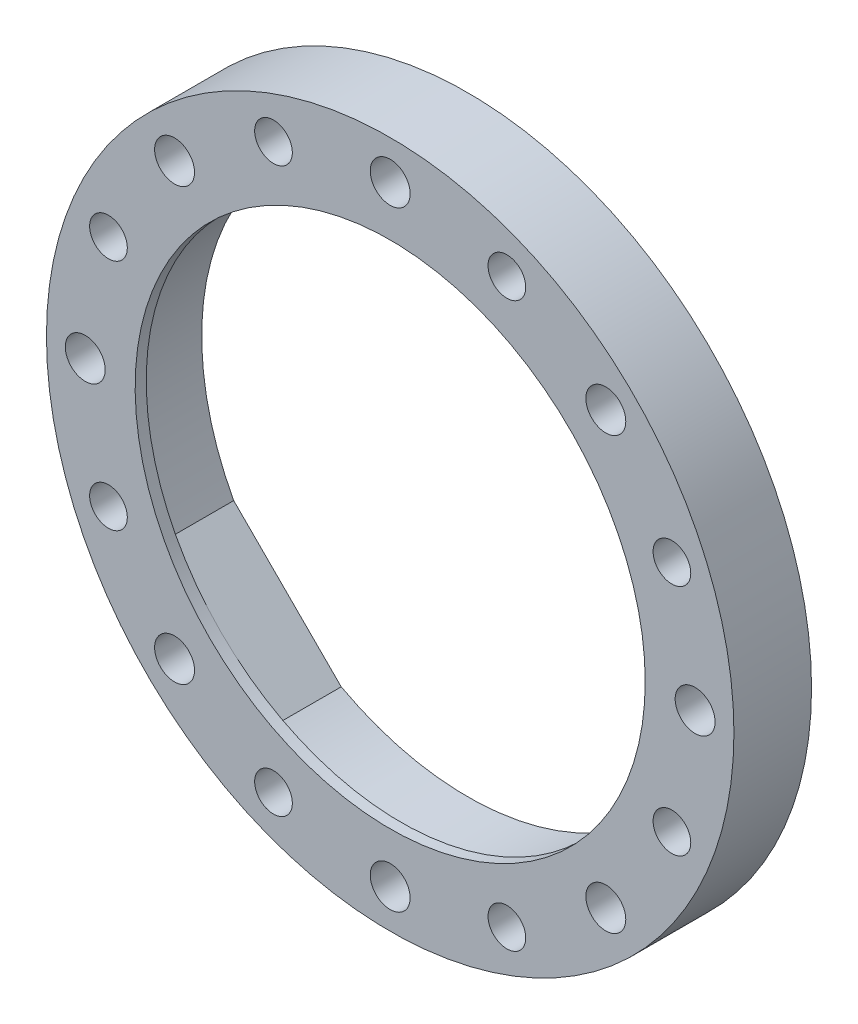
from build123d import *

# Parameters (mm, degrees)
SKETCH_1_R               = 31
EXTRUDE_1_DEPTH          = 6
SKETCH_2_R               = 24
CUT_EXTRUDE_1_DEPTH      = 45.24929378
EXTRUDE_2_DEPTH          = 6
SKETCH_5_R               = 31
SKETCH_5_R_2             = 23
EXTRUDE_3_DEPTH          = 1
HOLE_WIZARD_M3_1_D       = 3.6
PATTERN_CIRCULAR_1_COUNT = 8
HOLE_WIZARD_M3_2_D       = 3.4
PATTERN_CIRCULAR_4_COUNT = 8


with BuildPart() as part:
    # ｽｹｯﾁ1 → ﾎﾞｽ - 押し出し1 (new body)
    with BuildSketch(Plane.XY):
        Circle(SKETCH_1_R)
    extrude(amount=EXTRUDE_1_DEPTH)

    # ｽｹｯﾁ2 → ｶｯﾄ - 押し出し1 (cut, through all)
    with BuildSketch(Plane.XY.offset(6)):
        Circle(SKETCH_2_R)
    extrude(amount=-CUT_EXTRUDE_1_DEPTH, mode=Mode.SUBTRACT)

    # ｽｹｯﾁ3 → ﾎﾞｽ - 押し出し2 (add, through all)
    with BuildSketch(Plane.XY.offset(6)):
        with BuildLine():
            ThreePointArc((-11.41577611, 21.111135825), (-16.970562748, 16.970562748), (-21.111135825, 11.41577611))
            Line((-21.111135825, 11.41577611), (-11.41577611, 21.111135825))
        make_face()
        with BuildLine():
            Line((-11.41577611, -21.111135825), (-21.111135825, -11.41577611))
            ThreePointArc((-21.111135825, -11.41577611), (-16.970562748, -16.970562748), (-11.41577611, -21.111135825))
        make_face()
        with BuildLine():
            ThreePointArc((21.111135825, 11.41577611), (16.970562748, 16.970562748), (11.41577611, 21.111135825))
            Line((11.41577611, 21.111135825), (21.111135825, 11.41577611))
        make_face()
        with BuildLine():
            Line((21.111135825, -11.41577611), (11.41577611, -21.111135825))
            ThreePointArc((11.41577611, -21.111135825), (16.970562748, -16.970562748), (21.111135825, -11.41577611))
        make_face()
    extrude(amount=-EXTRUDE_2_DEPTH)

    # ｽｹｯﾁ5 → ﾎﾞｽ - 押し出し3 (add)
    with BuildSketch(Plane.XY.offset(6)):
        Circle(SKETCH_5_R)
        with Locations(Location((0, 0, 0), (0, 0, 225))):
            Circle(SKETCH_5_R_2, mode=Mode.SUBTRACT)
    extrude(amount=EXTRUDE_3_DEPTH)

    # M3 すきま穴1 (through all)
    with Locations(Plane.XY.offset(7)):
        with Locations((0, 27.5)):
            hole_wizard_m3_1 = Hole(HOLE_WIZARD_M3_1_D / 2)

    # 円形ﾊﾟﾀｰﾝ1: M3 すきま穴1 ×8 about axis
    pattern_circular_1_axis = Axis((0, 0, 0), (0, 0, 1))
    for i in range(1, PATTERN_CIRCULAR_1_COUNT):
        add(hole_wizard_m3_1.rotate(pattern_circular_1_axis, i * 360 / PATTERN_CIRCULAR_1_COUNT), mode=Mode.SUBTRACT)

    # M3 すきま穴2 (through all)
    with Locations(Plane.XY.offset(7)):
        with Locations((10.52379439, 25.406687144)):
            hole_wizard_m3_2 = Hole(HOLE_WIZARD_M3_2_D / 2)

    # 円形ﾊﾟﾀｰﾝ4: M3 すきま穴2 ×8 about axis
    pattern_circular_4_axis = Axis((0, 0, 0), (0, 0, 1))
    for i in range(1, PATTERN_CIRCULAR_4_COUNT):
        add(hole_wizard_m3_2.rotate(pattern_circular_4_axis, i * 360 / PATTERN_CIRCULAR_4_COUNT), mode=Mode.SUBTRACT)


solid = part.part
